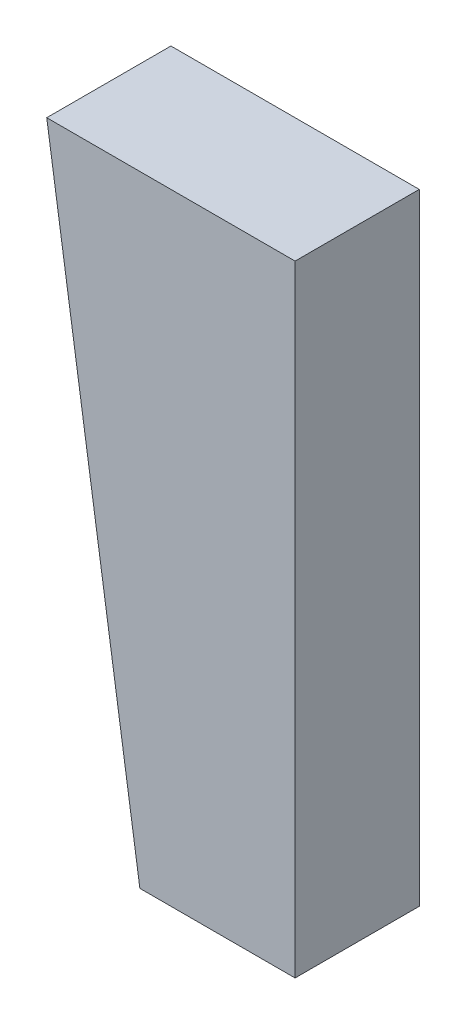
from build123d import *

# Parameters (mm, degrees)
BOSS_EXTRUDE1_DEPTH = 4


with BuildPart() as part:
    # Sketch1 → Boss-Extrude1 (new body)
    with BuildSketch(Plane.XY):
        Polygon((0, 0), (-5, 0), (-8, 20), (0, 20), align=None)
    extrude(amount=BOSS_EXTRUDE1_DEPTH)


solid = part.part
